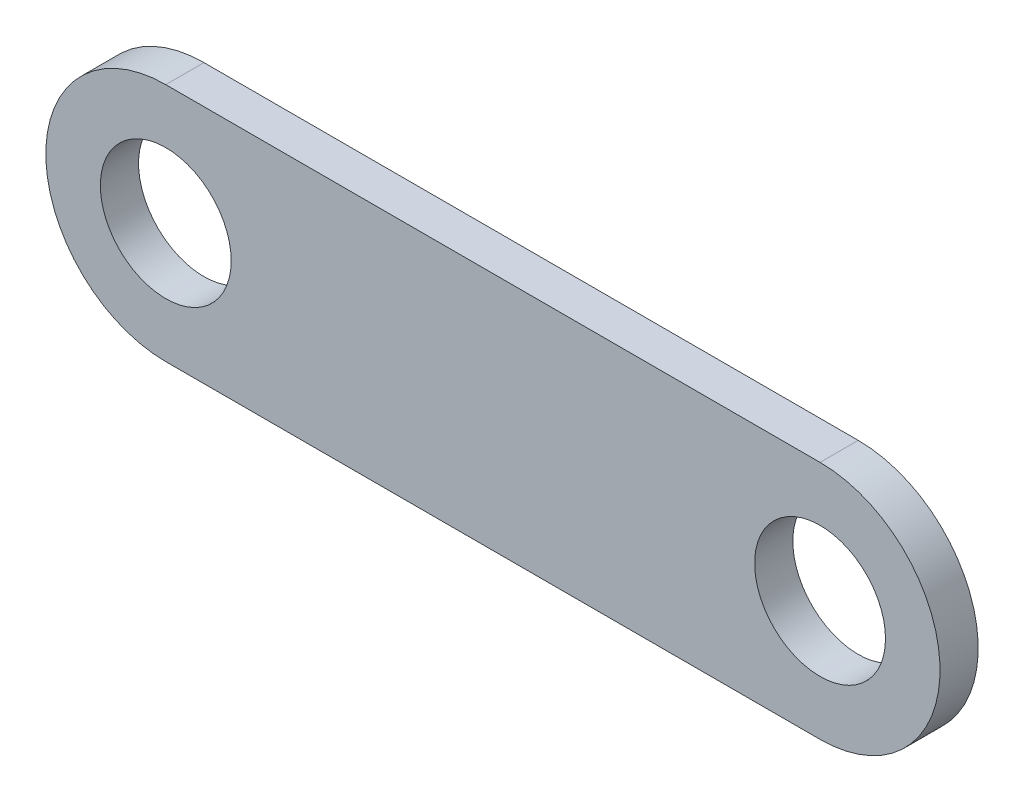
from build123d import *

# Parameters (mm, degrees)
SKETCH_1_R      = 6
EXTRUDE_1_DEPTH = 3.5


with BuildPart() as part:
    # 草图1 → 凸台-拉伸1 (new body)
    with BuildSketch(Plane.XY):
        with BuildLine():
            Line((30, 11), (-30, 11))
            ThreePointArc((-30, 11), (-41, 0), (-30, -11))
            Line((-30, -11), (30, -11))
            ThreePointArc((30, -11), (41, 0), (30, 11))
        make_face()
        with Locations((30, 0)):
            Circle(SKETCH_1_R, mode=Mode.SUBTRACT)
        with Locations((-30, 0)):
            Circle(SKETCH_1_R, mode=Mode.SUBTRACT)
    extrude(amount=EXTRUDE_1_DEPTH)


solid = part.part
